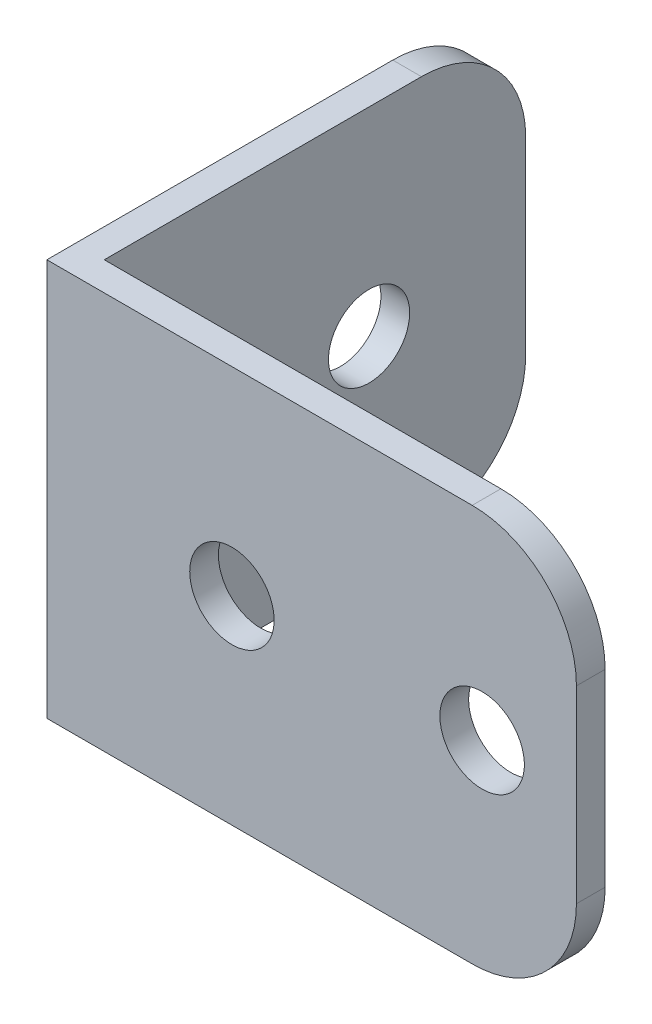
from build123d import *

# Parameters (mm, degrees)
BOSS_EXTRUDE1_DEPTH = 38.1
FILLET1_R           = 10
SKETCH2_R           = 4.05
CUT_EXTRUDE1_DEPTH  = 3.75336
SKETCH3_R           = 3.893907584
CUT_EXTRUDE2_DEPTH  = 3.75336


with BuildPart() as part:
    # Sketch1 → Boss-Extrude1 (new body)
    with BuildSketch(Plane(origin=(0, 0, 0), x_dir=(1, 0, 0), z_dir=(0, 1, 0))):
        Polygon((-25.4, -21.59), (25.4, -21.59), (25.4, -18.83664), (-22.64664, -18.83664), (-22.64664, 21.59), (-25.4, 21.59), align=None)
    extrude(amount=BOSS_EXTRUDE1_DEPTH)

    # Fillet1
    fillet1_edges = [part.edges().sort_by_distance(p)[0] for p in [
        (25.4, 38.1, 20.21332),
        (-24.02332, 38.1, -21.59),
        (-24.02332, 0, -21.59),
        (25.4, 0, 20.21332),
    ]]
    fillet(fillet1_edges, radius=FILLET1_R)

    # Sketch2 → Cut-Extrude1 (cut, through all)
    with BuildSketch(Plane(origin=(0, 0, 18.83664), x_dir=(-1, 0, 0), z_dir=(0, 0, -1))):
        with Locations((-16.35336, 19.05)):
            Circle(SKETCH2_R)
        with Locations((7.64664, 19.05)):
            Circle(SKETCH2_R)
    extrude(amount=-CUT_EXTRUDE1_DEPTH, mode=Mode.SUBTRACT)

    # Sketch3 → Cut-Extrude2 (cut, through all)
    with BuildSketch(Plane(origin=(-22.64664, 0, 0), x_dir=(0, 0, -1), z_dir=(1, 0, 0))):
        with Locations((6.56336, 19.05)):
            Circle(SKETCH3_R)
    extrude(amount=-CUT_EXTRUDE2_DEPTH, mode=Mode.SUBTRACT)


solid = part.part
